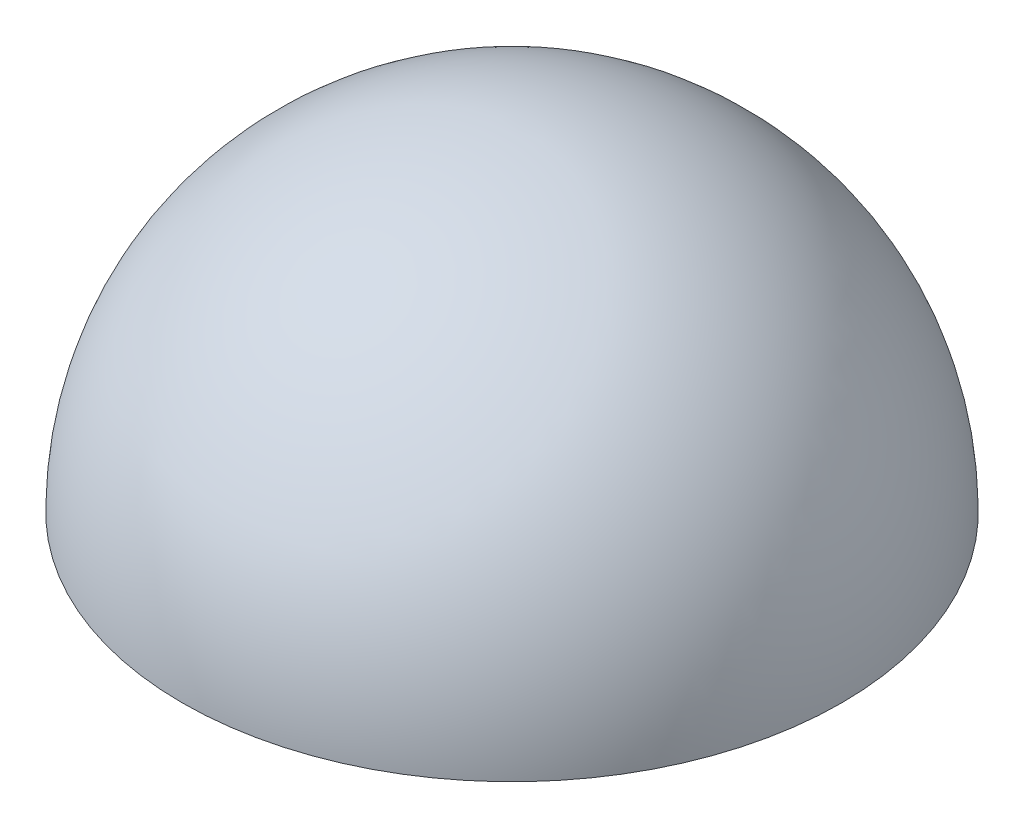
from build123d import *


with BuildPart() as part:
    # Sketch1 → Revolve3 (revolve)
    with BuildSketch(Plane.XY):
        with BuildLine():
            Line((0, 10), (0, 0))
            Line((0, 0), (10, 0))
            ThreePointArc((10, 0), (7.071067812, 7.071067812), (0, 10))
        make_face()
    revolve(axis=Axis((0, 10, 0), (0, -1, 0)))


solid = part.part
